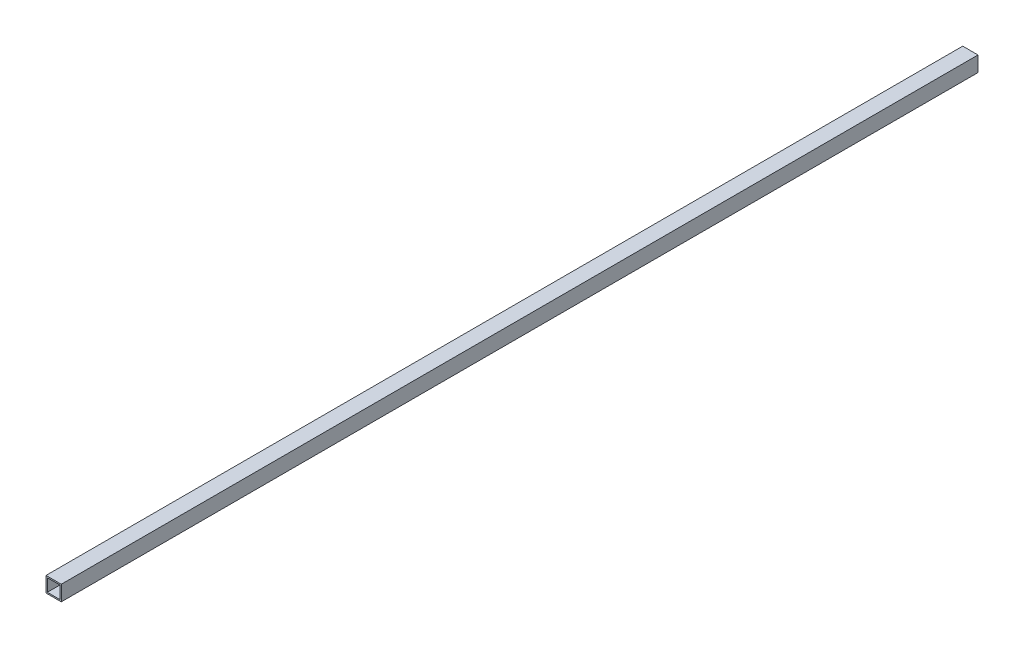
from build123d import *

# Parameters (mm, degrees)
SKETCH_1_W      = 25
SKETCH_1_H      = 25
SKETCH_1_W_2    = 20.6
SKETCH_1_H_2    = 20.6
EXTRUDE_1_DEPTH = 1500


with BuildPart() as part:
    # Эскиз1 → Вытянуть-Тонкостенный1 (new body)
    with BuildSketch(Plane.XY):
        with Locations((-32.387463795, 10.314685315)):
            Rectangle(SKETCH_1_W, SKETCH_1_H)
        with Locations((-32.387463795, 10.314685315)):
            Rectangle(SKETCH_1_W_2, SKETCH_1_H_2, mode=Mode.SUBTRACT)
    extrude(amount=EXTRUDE_1_DEPTH)


solid = part.part
